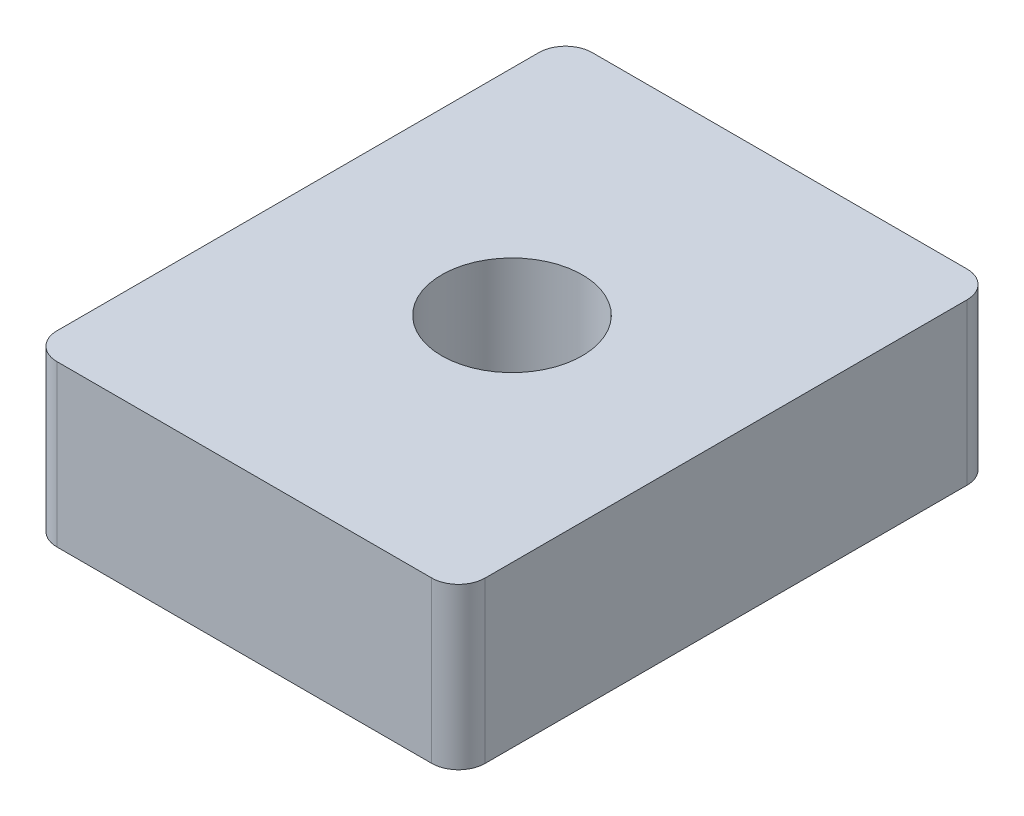
from build123d import *

# Parameters (mm, degrees)
SKETCH1_R           = 2.625
BOSS_EXTRUDE1_DEPTH = 6


with BuildPart() as part:
    # Sketch1 → Boss-Extrude1 (new body)
    with BuildSketch(Plane(origin=(0, 0, 0), x_dir=(1, 0, 0), z_dir=(0, 1, 0))):
        with BuildLine():
            Line((-7, 10), (7, 10))
            ThreePointArc((7, 10), (7.707106781, 9.707106781), (8, 9))
            Line((8, 9), (8, -9))
            ThreePointArc((8, -9), (7.707106781, -9.707106781), (7, -10))
            Line((7, -10), (-7, -10))
            ThreePointArc((-7, -10), (-7.707106781, -9.707106781), (-8, -9))
            Line((-8, -9), (-8, 9))
            ThreePointArc((-8, 9), (-7.707106781, 9.707106781), (-7, 10))
        make_face()
        Circle(SKETCH1_R, mode=Mode.SUBTRACT)
    extrude(amount=BOSS_EXTRUDE1_DEPTH)


solid = part.part
